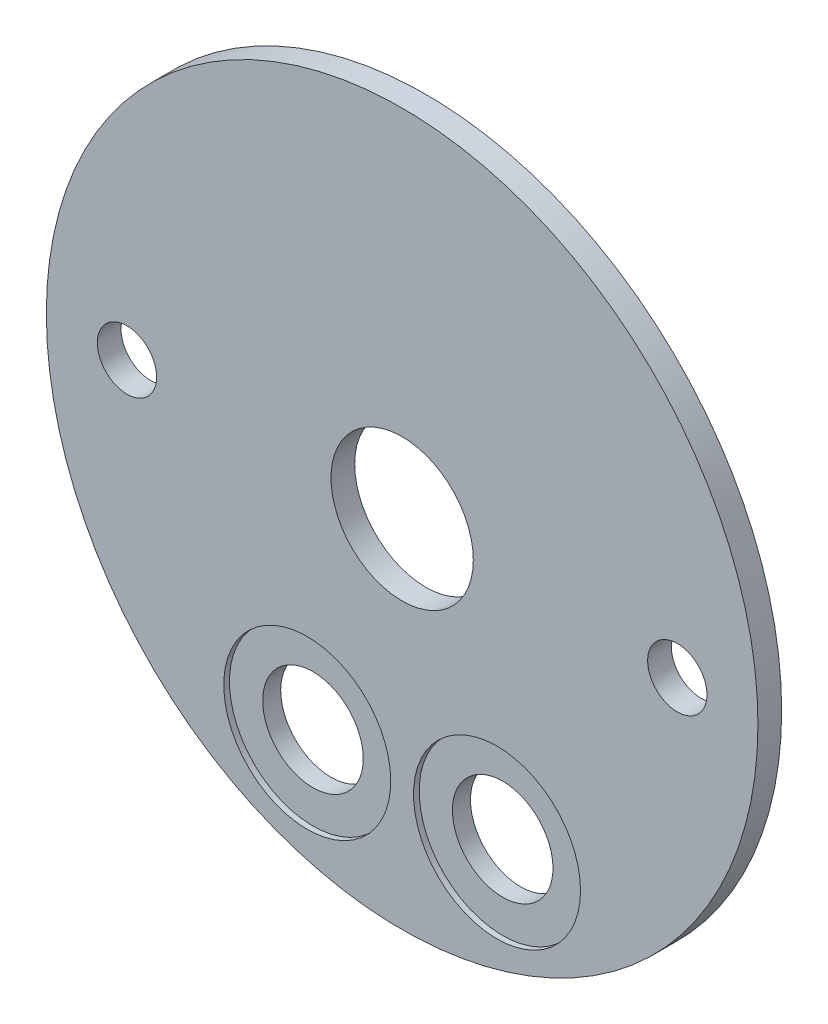
from build123d import *

# Parameters (mm, degrees)
SKETCH1_R           = 49.5046
BOSS_EXTRUDE1_DEPTH = 5.08
SKETCH2_R           = 47.625
BOSS_EXTRUDE2_DEPTH = 3.175
SKETCH3_R           = 6.731
SKETCH3_R_2         = 3.96875
SKETCH3_R_3         = 9.525
CUT_EXTRUDE1_DEPTH  = 9.255
SKETCH7_R           = 65.421404769
CUT_EXTRUDE3_DEPTH  = 5.08
SKETCH9_R           = 11.176
CUT_EXTRUDE5_DEPTH  = 0.762


with BuildPart() as part:
    # Sketch1 → Boss-Extrude1 (new body)
    with BuildSketch(Plane.XY):
        Circle(SKETCH1_R)
    extrude(amount=BOSS_EXTRUDE1_DEPTH)

    # Sketch2 → Boss-Extrude2 (add)
    with BuildSketch(Plane.XY.offset(5.08)):
        Circle(SKETCH2_R)
    extrude(amount=BOSS_EXTRUDE2_DEPTH)

    # Sketch3 → Cut-Extrude1 (cut, through all)
    with BuildSketch(Plane.XY.offset(8.255)):
        with Locations((-12.7, -31.166793627)):
            Circle(SKETCH3_R)
        with Locations((12.7, -31.166793627)):
            Circle(SKETCH3_R)
        with Locations((-36.83, 0)):
            Circle(SKETCH3_R_2)
        with Locations((36.83, 0)):
            Circle(SKETCH3_R_2)
        Circle(SKETCH3_R_3)
    extrude(amount=-CUT_EXTRUDE1_DEPTH, mode=Mode.SUBTRACT)

    # Sketch7 → Cut-Extrude3 (cut)
    with BuildSketch(Plane(origin=(0, 0, 0), x_dir=(-1, 0, 0), z_dir=(0, 0, -1))):
        Circle(SKETCH7_R)
    extrude(amount=-CUT_EXTRUDE3_DEPTH, mode=Mode.SUBTRACT)

    # Sketch9 → Cut-Extrude5 (cut)
    with BuildSketch(Plane.XY.offset(8.255)):
        with Locations((-12.7, -31.166793627)):
            Circle(SKETCH9_R)
        with Locations((12.7, -31.166793627)):
            Circle(SKETCH9_R)
    extrude(amount=-CUT_EXTRUDE5_DEPTH, mode=Mode.SUBTRACT)


solid = part.part
